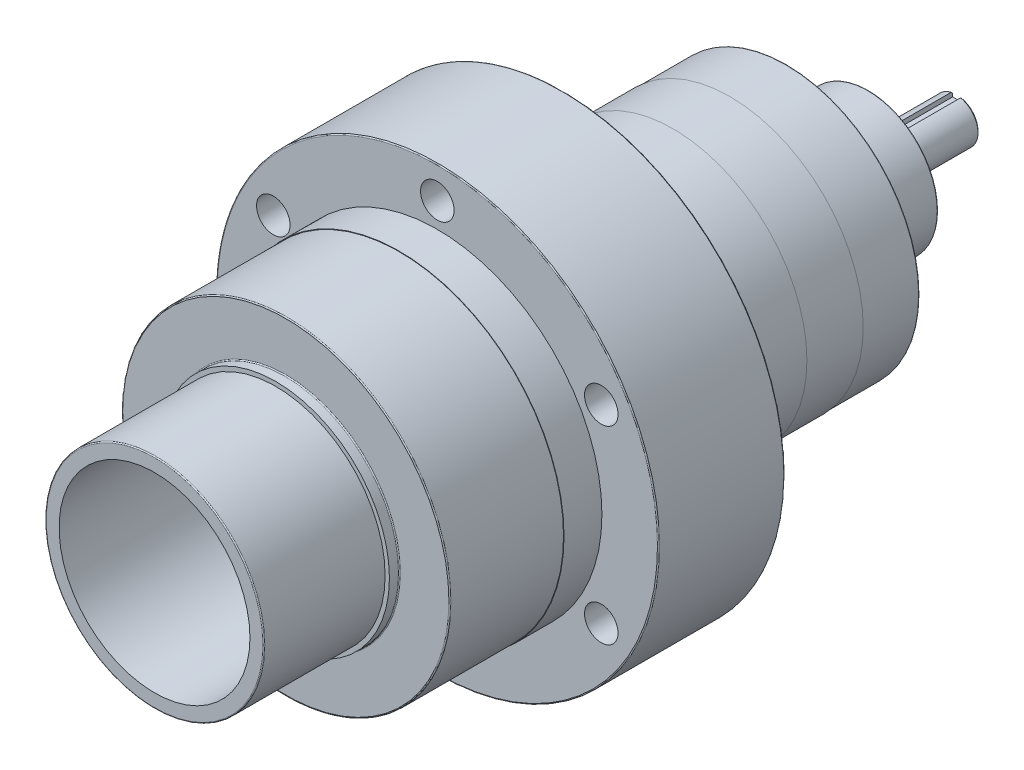
from build123d import *

# Parameters (mm, degrees)
SKETCH1_R                 = 28.575
EXTRUDE_E_DEPTH           = 33.02
SKETCH2_R                 = 28.575
SKETCH2_R_2               = 27.4955
FROM_DRAWING_DEPTH        = 30.5054
SKETCH3_R                 = 41.275
EXTRUDE_C_DEPTH           = 38.1
SKETCH4_R                 = 41.402
SKETCH4_R_2               = 41.275
BOSS_EXTRUDE3_DEPTH       = 9.525
SKETCH5_R                 = 55.626
BOSS_EXTRUDE4_DEPTH       = 31.75
CUT_EXTRUDE_START         = -66.04
SKETCH6_R                 = 24.003
CUT_EXTRUDE_F_DEPTH       = 66.04
SKETCH8_R                 = 33.401
EXTRUDE_D_DEPTH           = 56.134
BOSS_EXTRUDE6_START       = 14.2875
SKETCH9_R                 = 33.528
BOSS_EXTRUDE6_DEPTH       = 14.2875
SKETCH10_R                = 33.655
BOSS_EXTRUDE7_DEPTH       = 27.559
SKETCH11_R                = 20.066
FROM_DRAWING_2_DEPTH      = 6.35
SKETCH12_R                = 17.5006
EXTRUDE_Q_DEPTH           = 14.224
SKETCH13_R                = 5.5626
EXTRUDE_R_DEPTH           = 22.352
HOLE_WIZARD_S_D           = 8.4328
HOLE_WIZARD_S_CBORE_D     = 13.49502
HOLE_WIZARD_S_CBORE_DEPTH = 7.9375
CIRPATTERN1_COUNT         = 6
SKETCH16_R                = 13.081
SKETCH16_R_2              = 5.5626
CUT_EXTRUDE3_DEPTH        = 6.35
CUT_EXTRUDE_T_DEPTH       = 52.3842
CHAMFER1_SIZE             = 0.381
FILLET1_R                 = 0.254


with BuildPart() as part:
    # Sketch1 → Extrude E (new body)
    with BuildSketch(Plane.XY):
        Circle(SKETCH1_R)
    extrude(amount=-EXTRUDE_E_DEPTH)

    # Sketch2 → from drawing (cut)
    with BuildSketch(Plane.XY):
        Circle(SKETCH2_R)
        Circle(SKETCH2_R_2, mode=Mode.SUBTRACT)
    extrude(amount=-FROM_DRAWING_DEPTH, mode=Mode.SUBTRACT)

    # Sketch3 → Extrude C (add)
    with BuildSketch(Plane(origin=(0, 0, -33.02), x_dir=(-1, 0, 0), z_dir=(0, 0, -1))):
        with Locations(Location((0, 0, 0), (0, 0, 180))):  # turned: the seam where the file's is
            Circle(SKETCH3_R)
    extrude(amount=EXTRUDE_C_DEPTH)

    # Sketch4 → Boss-Extrude3 (add)
    with BuildSketch(Plane.XY.offset(-61.595)):
        Circle(SKETCH4_R)
        Circle(SKETCH4_R_2, mode=Mode.SUBTRACT)
    extrude(amount=-BOSS_EXTRUDE3_DEPTH)

    # Sketch5 → Boss-Extrude4 (add)
    with BuildSketch(Plane.XY.offset(-71.12)):
        Circle(SKETCH5_R)
    extrude(amount=-BOSS_EXTRUDE4_DEPTH)

    # Sketch6 → Cut-Extrude F (cut)
    with BuildSketch(Plane.XY.offset(CUT_EXTRUDE_START)):
        Circle(SKETCH6_R)
    extrude(amount=CUT_EXTRUDE_F_DEPTH, mode=Mode.SUBTRACT)

    # Sketch8 → Extrude D (add)
    with BuildSketch(Plane(origin=(0, 0, -102.87), x_dir=(-1, 0, 0), z_dir=(0, 0, -1))):
        with Locations(Location((0, 0, 0), (0, 0, 180))):  # turned: the seam where the file's is
            Circle(SKETCH8_R)
    extrude(amount=EXTRUDE_D_DEPTH)

    # Sketch9 → Boss-Extrude6 (add)
    with BuildSketch(Plane.XY.offset(-159.004).offset(BOSS_EXTRUDE6_START)):
        Circle(SKETCH9_R)
    extrude(amount=BOSS_EXTRUDE6_DEPTH)

    # Sketch10 → Boss-Extrude7 (add)
    with BuildSketch(Plane.XY.offset(-130.429)):
        Circle(SKETCH10_R)
    extrude(amount=BOSS_EXTRUDE7_DEPTH)

    # Sketch11 → from drawing 2 (add)
    with BuildSketch(Plane(origin=(0, 0, -159.004), x_dir=(-1, 0, 0), z_dir=(0, 0, -1))):
        with Locations(Location((0, 0, 0), (0, 0, 180))):  # turned: the seam where the file's is
            Circle(SKETCH11_R)
    extrude(amount=FROM_DRAWING_2_DEPTH)

    # Sketch12 → Extrude Q (add)
    with BuildSketch(Plane(origin=(0, 0, -165.354), x_dir=(-1, 0, 0), z_dir=(0, 0, -1))):
        with Locations(Location((0, 0, 0), (0, 0, 180))):  # turned: the seam where the file's is
            Circle(SKETCH12_R)
    extrude(amount=EXTRUDE_Q_DEPTH)

    # Sketch13 → Extrude R (add)
    with BuildSketch(Plane(origin=(0, 0, -179.578), x_dir=(-1, 0, 0), z_dir=(0, 0, -1))):
        with Locations(Location((0, 0, 0), (0, 0, 180))):  # turned: the seam where the file's is
            Circle(SKETCH13_R)
    extrude(amount=EXTRUDE_R_DEPTH)

    # Hole Wizard S (through all)
    with Locations(Plane(origin=(0, 0, -102.87), x_dir=(-1, 0, 0), z_dir=(0, 0, -1))):
        with Locations((0, -47.625)):
            hole_wizard_s = CounterBoreHole(HOLE_WIZARD_S_D / 2, HOLE_WIZARD_S_CBORE_D / 2, HOLE_WIZARD_S_CBORE_DEPTH)

    # CirPattern1: Hole Wizard S ×6 about axis
    cirpattern1_axis = Axis((0, 0, 0), (0, 0, 1))
    for i in range(1, CIRPATTERN1_COUNT):
        add(hole_wizard_s.rotate(cirpattern1_axis, i * 360 / CIRPATTERN1_COUNT), mode=Mode.SUBTRACT)

    # Sketch16 → Cut-Extrude3 (cut)
    with BuildSketch(Plane(origin=(0, 0, -179.578), x_dir=(-1, 0, 0), z_dir=(0, 0, -1))):
        Circle(SKETCH16_R)
        with Locations(Location((0, 0, 0), (0, 0, 180))):  # turned: the seam where the file's is
            Circle(SKETCH16_R_2, mode=Mode.SUBTRACT)
    extrude(amount=-CUT_EXTRUDE3_DEPTH, mode=Mode.SUBTRACT)

    # Sketch17 → Cut-Extrude T (cut, through all)
    with BuildSketch(Plane.XZ.offset(-4.2418)):
        with BuildLine():
            Line((-1.1938, -201.93), (-1.1938, -182.88))
            ThreePointArc((-1.1938, -182.88), (0, -181.6862), (1.1938, -182.88))
            Line((1.1938, -182.88), (1.1938, -201.93))
            ThreePointArc((1.1938, -201.93), (0, -203.1238), (-1.1938, -201.93))
        make_face()
    extrude(amount=-CUT_EXTRUDE_T_DEPTH, mode=Mode.SUBTRACT)

    # Chamfer1
    chamfer1_edges = [part.edges().sort_by_distance(p)[0] for p in [
        (-3.48582034, -4.334925065, -201.93),
    ]]
    chamfer(chamfer1_edges, length=CHAMFER1_SIZE)

    # Fillet1
    fillet1_edges = [part.edges().sort_by_distance(p)[0] for p in [
        (-27.4955, 0, 0),
        (-41.275, 0, -33.02),
        (-55.626, 0, -71.12),
        (-55.626, 0, -102.87),
        (-33.401, 0, -159.004),
        (-28.575, 0, -33.02),
        (-33.655, 0, -102.87),
        (-20.066, 0, -159.004),
        (-20.066, 0, -165.354),
        (-17.5006, 0, -165.354),
        (-17.5006, 0, -179.578),
    ]]
    fillet(fillet1_edges, radius=FILLET1_R)


solid = part.part
